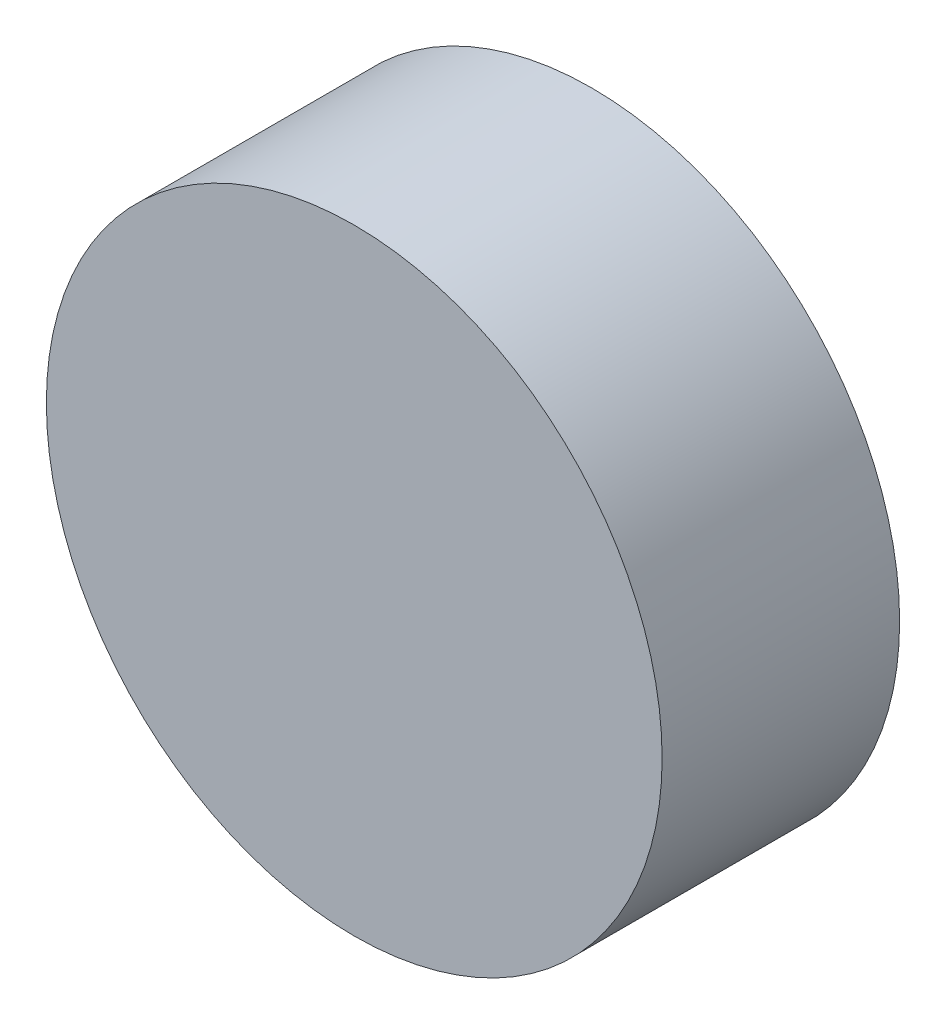
from build123d import *

# Parameters (mm, degrees)
SKETCH1_R           = 35
BOSS_EXTRUDE1_DEPTH = 13.5


with BuildPart() as part:
    # Sketch1 → Boss-Extrude1 (new body, symmetric)
    with BuildSketch(Plane.XY):
        Circle(SKETCH1_R)
    extrude(amount=BOSS_EXTRUDE1_DEPTH, both=True)


solid = part.part
